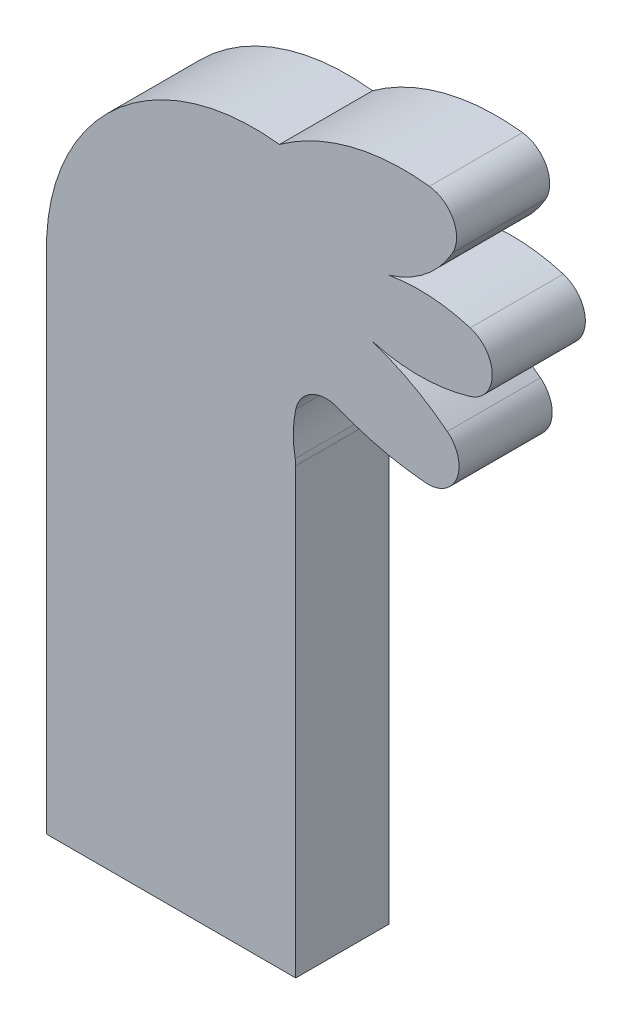
from build123d import *

# Parameters (mm, degrees)
SALIENTE_EXTRUIR1_DEPTH = 3


with BuildPart() as part:
    # Model → Saliente-Extruir1 (new body)
    with BuildSketch(Plane.XY):
        with BuildLine():
            Line((9.740547774, -46.101668317), (9.740547774, -31.803295278))
            ThreePointArc((9.740547774, -31.803295278), (9.736055246, -31.708612265), (9.722618028, -31.614779984))
            ThreePointArc((9.722618028, -31.614779984), (9.661571414, -30.916777437), (9.743772485, -30.220948989))
            ThreePointArc((9.743772485, -30.220948989), (10.255649641, -29.553355931), (11.095913023, -29.512659959))
            ThreePointArc((11.095913023, -29.512659959), (12.483349153, -29.956983983), (13.921978985, -30.186651266))
            ThreePointArc((13.921978985, -30.186651266), (14.934379735, -29.557617963), (14.625590492, -28.406406697))
            ThreePointArc((14.625590492, -28.406406697), (13.477036488, -27.648728099), (12.214507774, -27.101668317))
            ThreePointArc((12.214507774, -27.101668317), (13.791868666, -27.302020525), (15.363211574, -27.058936478))
            ThreePointArc((15.363211574, -27.058936478), (16.074009796, -26.101668317), (15.363211574, -25.144400157))
            ThreePointArc((15.363211574, -25.144400157), (14.062919208, -24.911447806), (12.743919539, -24.984021259))
            ThreePointArc((12.743919539, -24.984021259), (13.929279153, -24.357532563), (14.796143037, -23.334736147))
            ThreePointArc((14.796143037, -23.334736147), (14.817045797, -22.393544381), (14.0469262, -21.852069843))
            ThreePointArc((14.0469262, -21.852069843), (11.511931096, -22.017503021), (9.214507774, -23.101668317))
            ThreePointArc((9.214507774, -23.101668317), (4.080372041, -24.629353346), (1.714507774, -29.435168317))
            Line((1.714507774, -29.435168317), (1.714507774, -46.101668317))
            Line((1.714507774, -46.101668317), (9.740547774, -46.101668317))
        make_face()
    extrude(amount=SALIENTE_EXTRUIR1_DEPTH)


solid = part.part
